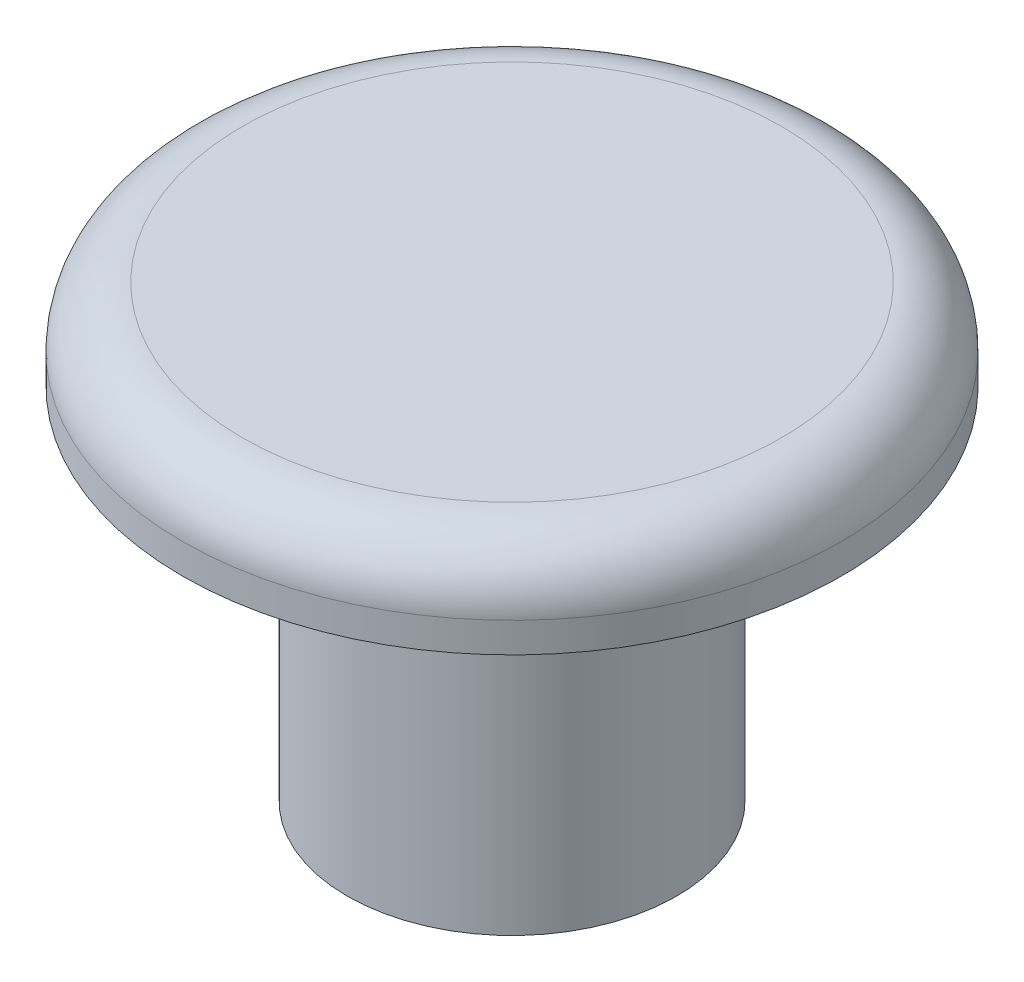
from build123d import *


with BuildPart() as part:
    # Sketch2 → Revolve1 (revolve)
    with BuildSketch(Plane.XY):
        with BuildLine():
            Line((0, 0), (-5.5, 0))
            Line((-5.5, 0), (-5.5, 12))
            Line((-5.5, 12), (-11, 12))
            Line((-11, 12), (-11, 13))
            ThreePointArc((-11, 13), (-10.414213562, 14.414213562), (-9, 15))
            Line((-9, 15), (0, 15))
            Line((0, 15), (0, 0))
        make_face()
    revolve(axis=Axis((0, 0, 0), (0, -1, 0)))


solid = part.part
